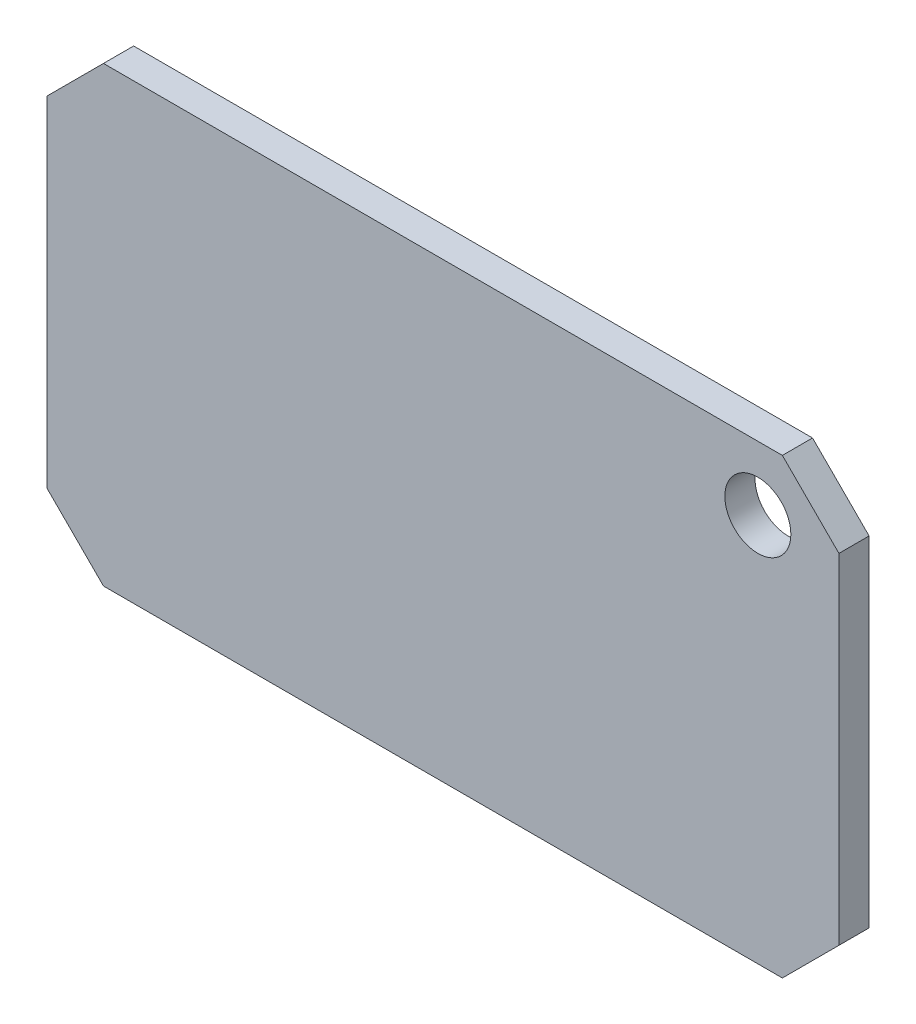
from build123d import *

# Parameters (mm, degrees)
SKETCH1_R           = 1.75
BOSS_EXTRUDE1_DEPTH = 1.6


with BuildPart() as part:
    # Sketch1 → Boss-Extrude1 (new body)
    with BuildSketch(Plane.XY):
        Polygon((-21, 9), (-18, 12), (18, 12), (21, 9), (21, -9), (18, -12), (-18, -12), (-21, -9), align=None)
        with Locations((16.7, 8.6)):
            Circle(SKETCH1_R, mode=Mode.SUBTRACT)
    extrude(amount=BOSS_EXTRUDE1_DEPTH)


solid = part.part
